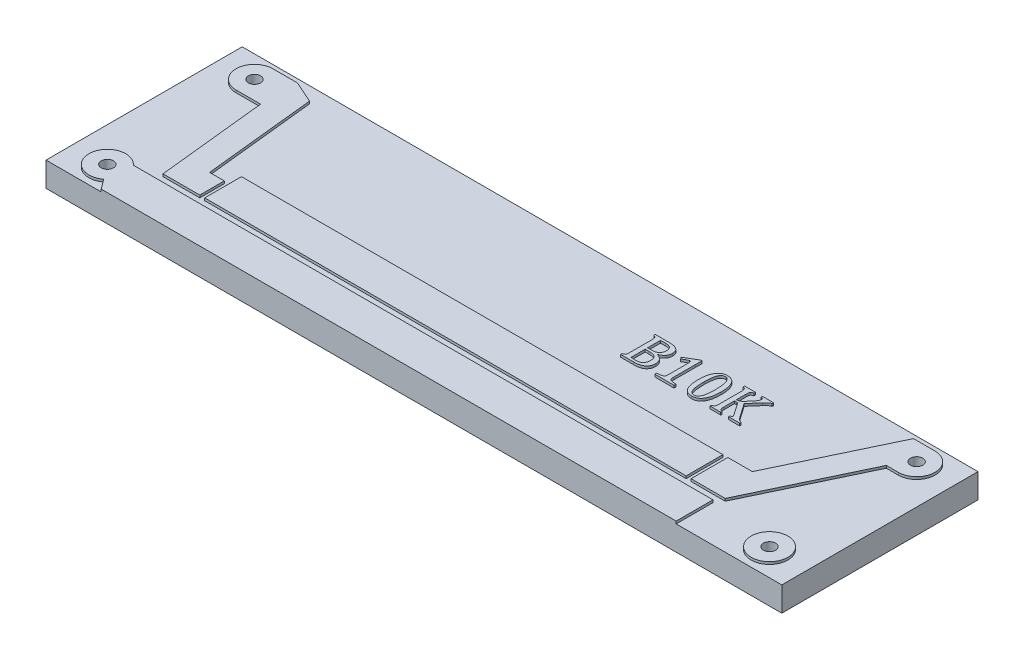
from build123d import *

# Parameters (mm, degrees)
SKETCH_1_W          = 30
SKETCH_1_H          = 8
EXTRUDE_1_DEPTH     = 1
SKETCH_2_R          = 0.25
CUT_EXTRUDE_1_DEPTH = 1.5
SKETCH_3_R          = 0.75
SKETCH_3_W          = 19.630277778
SKETCH_3_H          = 1.5
EXTRUDE_2_DEPTH     = 0.1
SKETCH_4_R          = 0.25
CUT_EXTRUDE_2_DEPTH = 10
EXTRUDE_3_DEPTH     = 0.1


with BuildPart() as part:
    # 草图1 → 凸台-拉伸1 (new body)
    with BuildSketch(Plane(origin=(0, 0, 0), x_dir=(1, 0, 0), z_dir=(0, 1, 0))):
        Rectangle(SKETCH_1_W, SKETCH_1_H)
    extrude(amount=EXTRUDE_1_DEPTH)

    # 草图2 → 切除-拉伸1 (cut, symmetric)
    with BuildSketch(Plane(origin=(0, 1, 0), x_dir=(1, 0, 0), z_dir=(0, 1, 0))):
        with Locations((-13.5, 3)):
            Circle(SKETCH_2_R)
        with Locations((13.5, 3)):
            Circle(SKETCH_2_R)
        with Locations((13.5, -3)):
            Circle(SKETCH_2_R)
        with Locations((-13.5, -3)):
            Circle(SKETCH_2_R)
    extrude(amount=CUT_EXTRUDE_1_DEPTH, both=True, mode=Mode.SUBTRACT)

    # 草图3 → 凸台-拉伸2 (add)
    with BuildSketch(Plane(origin=(0, 1, 0), x_dir=(1, 0, 0), z_dir=(0, 1, 0))):
        with Locations((13.5, -3)):
            Circle(SKETCH_3_R)
        with BuildLine():
            Line((10.693305081, -2.5), (-12.940983006, -2.5))
            ThreePointArc((-12.940983006, -2.5), (-14.246343636, -2.9260326), (-13.05, -3.6))
            Line((-13.05, -3.6), (-12.75, -4))
            Line((-12.75, -4), (10.693305081, -4))
            Line((10.693305081, -4), (10.693305081, -2.5))
        make_face()
        with BuildLine():
            Line((9.5, -0.7), (10.5, -0.7))
            Line((10.5, -0.7), (12.619047619, 3.75))
            Line((12.619047619, 3.75), (13.5, 3.75))
            ThreePointArc((13.5, 3.75), (14.25, 3), (13.5, 2.25))
            Line((13.5, 2.25), (13.0123527, 2.25))
            Line((13.0123527, 2.25), (10.893305081, -2.2))
            Line((10.893305081, -2.2), (9.5, -2.2))
            Line((9.5, -2.2), (9.5, -0.7))
        make_face()
        with BuildLine():
            Line((-13.5, 3.75), (-12.5, 3.75))
            Line((-12.5, 3.75), (-11.611050566, 3.354689573))
            Line((-11.611050566, 3.354689573), (-11.130277778, -1.2))
            Line((-11.130277778, -1.2), (-10.530277778, -1.2))
            Line((-10.530277778, -1.2), (-10.530277778, -2.2))
            Line((-10.530277778, -2.2), (-12.030277778, -2.2))
            Line((-12.030277778, -2.2), (-12.5, 2.25))
            Line((-12.5, 2.25), (-13.5, 2.25))
            ThreePointArc((-13.5, 2.25), (-14.25, 3), (-13.5, 3.75))
        make_face()
        with Locations((-0.515138889, -1.45)):
            Rectangle(SKETCH_3_W, SKETCH_3_H)
    extrude(amount=EXTRUDE_2_DEPTH)

    # 草图4 → 切除-拉伸2 (cut)
    with BuildSketch(Plane(origin=(0, 1.1, 0), x_dir=(1, 0, 0), z_dir=(0, 1, 0))):
        with Locations((13.5, 3)):
            Circle(SKETCH_4_R)
        with Locations((-13.5, 3)):
            Circle(SKETCH_4_R)
        with Locations((-13.5, -3)):
            Circle(SKETCH_4_R)
        with Locations((13.5, -3)):
            Circle(SKETCH_4_R)
    extrude(amount=-CUT_EXTRUDE_2_DEPTH, mode=Mode.SUBTRACT)

    # 草图5 → 凸台-拉伸3 (add)
    with BuildSketch(Plane(origin=(0, 1, 0), x_dir=(1, 0, 0), z_dir=(0, 1, 0))):
        with BuildLine():
            Line((3.675093502, 0.75252002), (3.675093502, 0.811316316))
            add(Edge.make_bspline(
                [(3.675093502, 0.811316316), (3.684941706, 0.81391048), (3.703100512, 0.818693782), (3.727290378, 0.827507364), (3.746416762, 0.83647328), (3.760811839, 0.846540586), (3.771095906, 0.858475927), (3.779444245, 0.87160991), (3.785625749, 0.887090397), (3.789789984, 0.905063786), (3.792793764, 0.926482094), (3.794793293, 0.952148806), (3.795989371, 0.982691887), (3.796031767, 1.004648681), (3.796054633, 1.016490892)],
                knots=[0, 0, 0, 0, 3.0539e-05, 5.6309e-05, 7.7126e-05, 9.3787e-05, 0.000108537, 0.000124086, 0.000140293, 0.000158267, 0.000179314, 0.000205127, 0.000235469, 0.000270993, 0.000270993, 0.000270993, 0.000270993], degree=3))
            Line((3.796054633, 1.016490892), (3.796054633, 1.899660259))
            add(Edge.make_bspline(
                [(3.796054633, 1.899660259), (3.79598915, 1.910582142), (3.795867337, 1.930899385), (3.795173472, 1.959002984), (3.793216667, 1.98227206), (3.790744444, 2.005850024), (3.785566123, 2.029221267), (3.775358722, 2.052060318), (3.760721587, 2.069179051), (3.74528947, 2.079976461), (3.729895844, 2.087018477), (3.714755932, 2.092828862), (3.696121377, 2.098843415), (3.682456375, 2.10273695), (3.675093502, 2.104834835)],
                knots=[0, 0, 0, 0, 3.2768e-05, 6.0956e-05, 8.4302e-05, 0.000102801, 0.000132066, 0.000155765, 0.000177056, 0.000198807, 0.000211684, 0.000227777, 0.000247436, 0.000270403, 0.000270403, 0.000270403, 0.000270403], degree=3))
            Line((3.675093502, 2.104834835), (3.675093502, 2.163631131))
            Line((3.675093502, 2.163631131), (4.238558009, 2.163631131))
            add(Edge.make_bspline(
                [(4.238558009, 2.163631131), (4.251828655, 2.16348574), (4.277766243, 2.163201571), (4.31567041, 2.161801766), (4.351594517, 2.158872546), (4.385487383, 2.155586614), (4.417251084, 2.149963574), (4.447184191, 2.144481229), (4.475113955, 2.137437524), (4.508840149, 2.126559428), (4.547123395, 2.110663419), (4.588017539, 2.087027199), (4.62237147, 2.058748963), (4.650358067, 2.025914408), (4.671642384, 1.988442146), (4.687267308, 1.946328178), (4.695884761, 1.899090215), (4.697012232, 1.866008609), (4.697597843, 1.848825961)],
                knots=[0, 0, 0, 0, 3.9815e-05, 7.7818e-05, 0.000113753, 0.000147943, 0.000179911, 0.000210481, 0.000239224, 0.000266243, 0.000316748, 0.000363281, 0.000407431, 0.000449582, 0.000491971, 0.000536057, 0.000583744, 0.000635282, 0.000635282, 0.000635282, 0.000635282], degree=3))
            add(Edge.make_bspline(
                [(4.697597843, 1.848825961), (4.697220991, 1.834404449), (4.696487344, 1.806328976), (4.689806888, 1.765791904), (4.679724156, 1.727951249), (4.664329575, 1.693532763), (4.645980007, 1.662023571), (4.624896783, 1.633223349), (4.601399105, 1.60701881), (4.574493487, 1.583853906), (4.544506862, 1.562505991), (4.51113376, 1.542081868), (4.47380282, 1.522334666), (4.447177717, 1.510484043), (4.43332074, 1.504316413)],
                knots=[0, 0, 0, 0, 4.3232e-05, 8.4163e-05, 0.000122946, 0.000160383, 0.000196886, 0.000232167, 0.000267288, 0.000302232, 0.000338436, 0.000377617, 0.000419535, 0.000465027, 0.000465027, 0.000465027, 0.000465027], degree=3))
            Line((4.43332074, 1.504316413), (4.43332074, 1.494210799))
            add(Edge.make_bspline(
                [(4.43332074, 1.494210799), (4.444707431, 1.490590303), (4.467009433, 1.48349919), (4.498810042, 1.470443937), (4.528790087, 1.456546953), (4.556274966, 1.440492785), (4.58177166, 1.423344192), (4.605355114, 1.404969329), (4.626367503, 1.384668022), (4.64548611, 1.363215701), (4.662269944, 1.340493009), (4.677192258, 1.316879282), (4.689425315, 1.291869057), (4.699491525, 1.265827495), (4.707577206, 1.238826744), (4.712988853, 1.210711141), (4.716451295, 1.181635475), (4.716946087, 1.161858339), (4.717196608, 1.151844866)],
                knots=[0, 0, 0, 0, 3.583e-05, 7.0177e-05, 0.000103053, 0.000134883, 0.000165544, 0.000195196, 0.000224436, 0.000253072, 0.000281306, 0.000309093, 0.000336757, 0.000364679, 0.000392779, 0.000421186, 0.000450473, 0.000480508, 0.000480508, 0.000480508, 0.000480508], degree=3))
            add(Edge.make_bspline(
                [(4.717196608, 1.151844866), (4.717059852, 1.140302097), (4.716793084, 1.117785687), (4.713560879, 1.084861856), (4.708763744, 1.053650799), (4.702026758, 1.023934921), (4.693198611, 0.995876534), (4.682386397, 0.969383584), (4.669963215, 0.944422749), (4.650218555, 0.913944758), (4.621397241, 0.879126927), (4.580300922, 0.843245694), (4.532574638, 0.813933621), (4.478886881, 0.790756064), (4.419160036, 0.773429599), (4.353667678, 0.761612432), (4.282338712, 0.753660428), (4.232763129, 0.752909836), (4.207016245, 0.75252002)],
                knots=[0, 0, 0, 0, 3.4616e-05, 6.7526e-05, 9.9143e-05, 0.000129303, 0.000158843, 0.000187277, 0.000215078, 0.000242346, 0.000296062, 0.000350106, 0.000405256, 0.000463401, 0.000525028, 0.000591395, 0.000662852, 0.000740061, 0.000740061, 0.000740061, 0.000740061], degree=3))
            Line((4.207016245, 0.75252002), (3.675093502, 0.75252002))
        make_face()
        with BuildLine():
            add(Edge.make_bspline(
                [(4.167818715, 1.536470637), (4.180177863, 1.536715916), (4.204127252, 1.537191214), (4.239041435, 1.540573947), (4.271748264, 1.546251306), (4.302170928, 1.554540814), (4.330257531, 1.564996441), (4.356220727, 1.577525232), (4.379963181, 1.592626216), (4.401447839, 1.610096688), (4.420558405, 1.629837428), (4.437249794, 1.651651952), (4.451054034, 1.675821025), (4.462358439, 1.701933032), (4.471269725, 1.730044898), (4.47771589, 1.760177922), (4.481339212, 1.792492178), (4.481783013, 1.814723266), (4.482011423, 1.826164889)],
                knots=[0, 0, 0, 0, 3.7074e-05, 7.1842e-05, 0.000105121, 0.000136545, 0.000166294, 0.000194918, 0.000222867, 0.000250511, 0.000277798, 0.000305115, 0.000332691, 0.000361079, 0.000390327, 0.000421019, 0.000453383, 0.000487702, 0.000487702, 0.000487702, 0.000487702], degree=3))
            add(Edge.make_bspline(
                [(4.482011423, 1.826164889), (4.481665151, 1.837297328), (4.480998862, 1.858718136), (4.477416871, 1.88944673), (4.469788603, 1.91698984), (4.460101412, 1.941741826), (4.447641594, 1.963842444), (4.432894738, 1.983374178), (4.416260138, 2.000948198), (4.397074865, 2.015431364), (4.376295078, 2.028254028), (4.35360842, 2.038768161), (4.329212747, 2.047911811), (4.293538368, 2.056568687), (4.245621086, 2.06438517), (4.206238324, 2.065210694), (4.185886326, 2.065637304)],
                knots=[0, 0, 0, 0, 3.3414e-05, 6.4295e-05, 9.2523e-05, 0.000118909, 0.000143864, 0.000168363, 0.000192186, 0.000216197, 0.000240251, 0.000265319, 0.00029109, 0.000318274, 0.000375316, 0.000436318, 0.000436318, 0.000436318, 0.000436318], degree=3))
            add(Edge.make_bspline(
                [(4.185886326, 2.065637304), (4.179046546, 2.065683703), (4.164343471, 2.065783444), (4.140770508, 2.064911579), (4.114122234, 2.064471681), (4.085646689, 2.063484546), (4.057575509, 2.062602433), (4.032246112, 2.061860558), (4.010828356, 2.060459167), (3.997861338, 2.059805864), (3.992042287, 2.05951269)],
                knots=[0, 0, 0, 0, 2.0517e-05, 4.4105e-05, 7.0754e-05, 0.000100473, 0.000129579, 0.000155013, 0.000176484, 0.000193963, 0.000193963, 0.000193963, 0.000193963], degree=3))
            Line((3.992042287, 2.05951269), (3.992042287, 1.536470637))
            Line((3.992042287, 1.536470637), (4.167818715, 1.536470637))
        make_face(mode=Mode.SUBTRACT)
        with BuildLine():
            add(Edge.make_bspline(
                [(3.992042287, 0.857557153), (4.004694354, 0.856455504), (4.030688471, 0.854192127), (4.070833433, 0.852283466), (4.113090006, 0.850497226), (4.141991029, 0.850508217), (4.156794409, 0.850513847)],
                knots=[0, 0, 0, 0, 3.8096e-05, 7.8269e-05, 0.000120557, 0.000164961, 0.000164961, 0.000164961, 0.000164961], degree=3))
            add(Edge.make_bspline(
                [(4.156794409, 0.850513847), (4.177636871, 0.850872698), (4.217085008, 0.85155189), (4.272451687, 0.857902591), (4.320616172, 0.868016616), (4.361846295, 0.882546623), (4.396466687, 0.902081717), (4.426288137, 0.924746049), (4.450349245, 0.952222219), (4.469764223, 0.983447035), (4.483996158, 1.018972633), (4.494362581, 1.058354948), (4.500430655, 1.101947249), (4.50120594, 1.132328677), (4.501610188, 1.148170097)],
                knots=[0, 0, 0, 0, 6.2508e-05, 0.000118307, 0.000166902, 0.000209914, 0.000248848, 0.000285725, 0.000321735, 0.000357766, 0.000395527, 0.000436084, 0.000479695, 0.000527209, 0.000527209, 0.000527209, 0.000527209], degree=3))
            add(Edge.make_bspline(
                [(4.501610188, 1.148170097), (4.501257896, 1.163915423), (4.500581741, 1.194135392), (4.493825507, 1.237361398), (4.4825446, 1.276301829), (4.466931097, 1.311131902), (4.446429178, 1.34188808), (4.420555817, 1.36803342), (4.390107644, 1.390528101), (4.354094214, 1.40831891), (4.312363363, 1.422129346), (4.264015286, 1.431546198), (4.208811031, 1.43776414), (4.169573579, 1.438230362), (4.148832411, 1.43847681)],
                knots=[0, 0, 0, 0, 4.7208e-05, 9.0607e-05, 0.000130821, 0.000168507, 0.000204689, 0.00024107, 0.00027831, 0.000317752, 0.000361038, 0.000409805, 0.000465266, 0.000527458, 0.000527458, 0.000527458, 0.000527458], degree=3))
            Line((4.148832411, 1.43847681), (3.992042287, 1.43847681))
            Line((3.992042287, 1.43847681), (3.992042287, 0.857557153))
        make_face(mode=Mode.SUBTRACT)
        with BuildLine():
            add(Edge.make_bspline(
                [(5.559943522, 1.025371582), (5.5599119, 1.01597523), (5.559852731, 0.998392676), (5.561731365, 0.973915842), (5.563129847, 0.952989397), (5.567062448, 0.930806326), (5.57470515, 0.907509455), (5.58984609, 0.883801888), (5.613068919, 0.866558745), (5.642833415, 0.853333749), (5.680474364, 0.844672753), (5.716886032, 0.838867766), (5.751214813, 0.835928791), (5.781944535, 0.833832197), (5.816649346, 0.831911116), (5.841060844, 0.831258822), (5.853925003, 0.830915082)],
                knots=[0, 0, 0, 0, 2.8175e-05, 5.2721e-05, 7.3626e-05, 9.1046e-05, 0.000120196, 0.000146695, 0.000173956, 0.000205611, 0.000243862, 0.000289425, 0.00031618, 0.000347183, 0.000381836, 0.00042044, 0.00042044, 0.00042044, 0.00042044], degree=3))
            Line((5.853925003, 0.830915082), (5.853925003, 0.75252002))
            Line((5.853925003, 0.75252002), (5.069974386, 0.75252002))
            Line((5.069974386, 0.75252002), (5.069974386, 0.830915082))
            add(Edge.make_bspline(
                [(5.069974386, 0.830915082), (5.088047143, 0.831742573), (5.12145711, 0.833272303), (5.167396807, 0.836666779), (5.20498529, 0.840216093), (5.235187181, 0.844073118), (5.259752912, 0.849108382), (5.280463772, 0.855107735), (5.298296237, 0.862136839), (5.313348966, 0.870428759), (5.32599325, 0.880476098), (5.336368424, 0.892356785), (5.345544535, 0.905532607), (5.352322081, 0.921393671), (5.35814645, 0.940409393), (5.361225887, 0.964153953), (5.363902447, 0.99274733), (5.363937113, 1.013520749), (5.363955867, 1.024759121)],
                knots=[0, 0, 0, 0, 5.4273e-05, 0.000100331, 0.000138176, 0.000167539, 0.000191623, 0.000213328, 0.000232151, 0.000249016, 0.000264702, 0.000280317, 0.0002962, 0.000312648, 0.000331831, 0.000355695, 0.00038428, 0.000417971, 0.000417971, 0.000417971, 0.000417971], degree=3))
            Line((5.363955867, 1.024759121), (5.363955867, 1.86138142))
            add(Edge.make_bspline(
                [(5.363955867, 1.86138142), (5.363817989, 1.867826737), (5.36356259, 1.879765702), (5.360766959, 1.896342551), (5.356469396, 1.910292584), (5.349721611, 1.921495686), (5.341485461, 1.930331678), (5.331109735, 1.936284785), (5.319207126, 1.940120389), (5.310602406, 1.940497106), (5.306078263, 1.940695174)],
                knots=[0, 0, 0, 0, 1.9314e-05, 3.5777e-05, 5.0303e-05, 6.2802e-05, 7.4714e-05, 8.611e-05, 9.8313e-05, 0.000111843, 0.000111843, 0.000111843, 0.000111843], degree=3))
            add(Edge.make_bspline(
                [(5.306078263, 1.940695174), (5.299917194, 1.94018634), (5.28610667, 1.939045749), (5.263895522, 1.931941754), (5.238303504, 1.920641762), (5.208929288, 1.905634717), (5.176395343, 1.886329293), (5.139839139, 1.864358701), (5.099750523, 1.838876801), (5.071984774, 1.820495921), (5.057418927, 1.810853353)],
                knots=[0, 0, 0, 0, 1.8498e-05, 4.1466e-05, 6.9452e-05, 0.000102458, 0.000140328, 0.000182921, 0.000230411, 0.000282816, 0.000282816, 0.000282816, 0.000282816], degree=3))
            Line((5.057418927, 1.810853353), (5.01117809, 1.890473338))
            Line((5.01117809, 1.890473338), (5.506965609, 2.183229896))
            Line((5.506965609, 2.183229896), (5.566068136, 2.183229896))
            add(Edge.make_bspline(
                [(5.566068136, 2.183229896), (5.565530236, 2.174554873), (5.564404284, 2.156395971), (5.563211018, 2.128013133), (5.562397529, 2.097281166), (5.56134528, 2.064111333), (5.56089079, 2.028480685), (5.560159586, 1.990511236), (5.55988384, 1.950188686), (5.559923192, 1.922525475), (5.559943522, 1.908234719)],
                knots=[0, 0, 0, 0, 2.6075e-05, 5.458e-05, 8.5217e-05, 0.000118303, 0.000154137, 0.000192115, 0.000232232, 0.000275104, 0.000275104, 0.000275104, 0.000275104], degree=3))
            Line((5.559943522, 1.908234719), (5.559943522, 1.025371582))
        make_face()
        with BuildLine():
            add(Edge.make_bspline(
                [(6.587347553, 0.732921255), (6.569348192, 0.73341637), (6.534373099, 0.734378443), (6.483767868, 0.742804919), (6.436703198, 0.756561226), (6.393126627, 0.776023428), (6.352984456, 0.80086689), (6.316792662, 0.831726227), (6.284166328, 0.867920428), (6.25485781, 0.909605479), (6.229605033, 0.957170501), (6.207546287, 1.010191399), (6.188942454, 1.068802011), (6.174198842, 1.13317812), (6.162274884, 1.203100921), (6.153801596, 1.278754296), (6.149043411, 1.360122292), (6.148293907, 1.416217803), (6.147906485, 1.445213886)],
                knots=[0, 0, 0, 0, 5.3967e-05, 0.000104865, 0.000153409, 0.000200702, 0.000247607, 0.000294541, 0.000342888, 0.000393439, 0.000447012, 0.000504112, 0.000565513, 0.000631251, 0.000702085, 0.000778209, 0.000859508, 0.000946497, 0.000946497, 0.000946497, 0.000946497], degree=3))
            add(Edge.make_bspline(
                [(6.147906485, 1.445213886), (6.148318058, 1.475949365), (6.149113362, 1.535341082), (6.155176201, 1.621130599), (6.165398033, 1.700531838), (6.180112838, 1.773549857), (6.198312808, 1.840417681), (6.220090271, 1.901156064), (6.245011636, 1.955945977), (6.273661492, 2.004603042), (6.305083686, 2.04769551), (6.340305809, 2.084171686), (6.377921471, 2.115517537), (6.418989256, 2.140196509), (6.462322454, 2.159793417), (6.507943394, 2.172983395), (6.555265701, 2.181755428), (6.587511415, 2.182733358), (6.603884012, 2.183229896)],
                knots=[0, 0, 0, 0, 9.22e-05, 0.000178163, 0.000257854, 0.000332204, 0.000401445, 0.000465571, 0.000525586, 0.00058173, 0.000634709, 0.000685174, 0.00073348, 0.000781168, 0.000828461, 0.000875743, 0.00092332, 0.000972395, 0.000972395, 0.000972395, 0.000972395], degree=3))
            add(Edge.make_bspline(
                [(6.603884012, 2.183229896), (6.622086588, 2.182734625), (6.657465738, 2.181771998), (6.708782493, 2.173326356), (6.756479272, 2.159551065), (6.800888938, 2.140617538), (6.841192266, 2.115436423), (6.878213486, 2.08519948), (6.910918836, 2.04885553), (6.94061458, 2.007576616), (6.966212202, 1.960395164), (6.989024087, 1.908041617), (7.007271366, 1.849696417), (7.023115361, 1.78615063), (7.034579726, 1.716785206), (7.043701026, 1.64202433), (7.048273462, 1.56153618), (7.049048785, 1.506056145), (7.049449694, 1.47736811)],
                knots=[0, 0, 0, 0, 5.4579e-05, 0.000106081, 0.000155507, 0.000203236, 0.000250402, 0.00029761, 0.000346163, 0.000396642, 0.000449824, 0.000506882, 0.0005677, 0.000632985, 0.000703216, 0.000778462, 0.000858844, 0.000944915, 0.000944915, 0.000944915, 0.000944915], degree=3))
            add(Edge.make_bspline(
                [(7.049449694, 1.47736811), (7.049123671, 1.447654279), (7.04849231, 1.390111861), (7.042882728, 1.306512335), (7.033930096, 1.22848312), (7.021092439, 1.155966577), (7.004883185, 1.088999156), (6.98413472, 1.027779513), (6.960551511, 0.971821996), (6.932963687, 0.921544052), (6.90163795, 0.87714407), (6.866870178, 0.838484004), (6.828745989, 0.805733376), (6.787001064, 0.778957418), (6.741884297, 0.758099124), (6.693257052, 0.743325679), (6.641345094, 0.734728749), (6.605651729, 0.733533962), (6.587347553, 0.732921255)],
                knots=[0, 0, 0, 0, 8.9132e-05, 0.000172609, 0.000251236, 0.000324642, 0.000393418, 0.000457719, 0.000518356, 0.000575375, 0.000629414, 0.000681016, 0.000730972, 0.000779731, 0.00082933, 0.000879605, 0.000931761, 0.000986662, 0.000986662, 0.000986662, 0.000986662], degree=3))
        make_face()
        with BuildLine():
            add(Edge.make_bspline(
                [(6.343894139, 1.476449418), (6.344026113, 1.448782984), (6.344281384, 1.395269153), (6.347481819, 1.317870296), (6.352136359, 1.24615026), (6.359177648, 1.180266974), (6.367987528, 1.120079378), (6.37847205, 1.065522019), (6.391231131, 1.016567678), (6.406201401, 0.973264905), (6.422934497, 0.935027677), (6.442226778, 0.90218563), (6.463438769, 0.874027297), (6.487127459, 0.851064841), (6.51326202, 0.833263221), (6.541550245, 0.820590051), (6.57200428, 0.812553113), (6.593115434, 0.811734091), (6.603884012, 0.811316316)],
                knots=[0, 0, 0, 0, 8.2994e-05, 0.00016053, 0.000232356, 0.000298571, 0.000359246, 0.000414799, 0.000465159, 0.000510871, 0.000552131, 0.000590156, 0.000624884, 0.000657588, 0.000688675, 0.000719239, 0.000750211, 0.000782458, 0.000782458, 0.000782458, 0.000782458], degree=3))
            add(Edge.make_bspline(
                [(6.603884012, 0.811316316), (6.614133178, 0.811792169), (6.634269175, 0.812727052), (6.663301499, 0.819936119), (6.690427928, 0.831821517), (6.715144043, 0.848839714), (6.737915045, 0.870473074), (6.758382852, 0.896756273), (6.776838071, 0.927729826), (6.792913971, 0.96358341), (6.807256193, 1.004259891), (6.819791593, 1.049992652), (6.829878694, 1.10101559), (6.838846616, 1.156961209), (6.845511379, 1.218182744), (6.849771786, 1.284499463), (6.85310783, 1.356067587), (6.853341111, 1.405501543), (6.85346204, 1.431127273)],
                knots=[0, 0, 0, 0, 3.0721e-05, 6.0356e-05, 8.9148e-05, 0.00011913, 0.000149891, 0.000183035, 0.000218747, 0.000257802, 0.00030071, 0.000348035, 0.000399924, 0.000456664, 0.000517975, 0.000584586, 0.000656003, 0.000732872, 0.000732872, 0.000732872, 0.000732872], degree=3))
            add(Edge.make_bspline(
                [(6.85346204, 1.431127273), (6.85329367, 1.450828477), (6.852964752, 1.489315605), (6.851882984, 1.54567815), (6.849514409, 1.599191628), (6.845645989, 1.649701633), (6.841614652, 1.697326867), (6.836002705, 1.742036401), (6.82966399, 1.783920402), (6.822360567, 1.822953989), (6.813961803, 1.859157107), (6.805327629, 1.892869072), (6.795312431, 1.9238273), (6.785339295, 1.952411903), (6.773319715, 1.97778973), (6.761667423, 2.000971478), (6.748694379, 2.021350391), (6.73078131, 2.044425036), (6.706569057, 2.068656381), (6.673392904, 2.089754453), (6.636963912, 2.102715326), (6.611541405, 2.10412272), (6.59867809, 2.104834835)],
                knots=[0, 0, 0, 0, 5.9106e-05, 0.000115465, 0.000169112, 0.000219773, 0.000267432, 0.000312481, 0.000354924, 0.000394504, 0.000431573, 0.000466409, 0.000498854, 0.000529177, 0.000557131, 0.000583018, 0.000606975, 0.000629455, 0.000670599, 0.000709001, 0.000746576, 0.000785061, 0.000785061, 0.000785061, 0.000785061], degree=3))
            add(Edge.make_bspline(
                [(6.59867809, 2.104834835), (6.587096918, 2.104310187), (6.564563613, 2.103289389), (6.532203114, 2.095207154), (6.502765136, 2.081491568), (6.47651718, 2.062085629), (6.453017745, 2.037751465), (6.432212464, 2.008651999), (6.413842315, 1.974844544), (6.397674557, 1.936475612), (6.384124668, 1.893449279), (6.372501635, 1.846085294), (6.363139912, 1.794324633), (6.355938686, 1.738296746), (6.350572255, 1.678220452), (6.346524568, 1.614301775), (6.344564748, 1.546588358), (6.344121549, 1.50023424), (6.343894139, 1.476449418)],
                knots=[0, 0, 0, 0, 3.4714e-05, 6.7542e-05, 9.9325e-05, 0.000131543, 0.000164893, 0.000200421, 0.000238523, 0.000280101, 0.000325133, 0.000373707, 0.000426324, 0.000482844, 0.000543117, 0.000607243, 0.000674954, 0.000746312, 0.000746312, 0.000746312, 0.000746312], degree=3))
        make_face(mode=Mode.SUBTRACT)
        with BuildLine():
            Line((7.636493965, 1.516871872), (7.667423267, 1.516871872))
            add(Edge.make_bspline(
                [(7.667423267, 1.516871872), (7.680034274, 1.51741676), (7.704395506, 1.518469343), (7.734151205, 1.526466273), (7.756690794, 1.536804496), (7.774587457, 1.54731244), (7.793026217, 1.561015977), (7.809460878, 1.574018994), (7.823162985, 1.58692826), (7.835636949, 1.598020678), (7.848608857, 1.611906878), (7.863704237, 1.626833647), (7.879523638, 1.644279513), (7.897136479, 1.663131138), (7.915579548, 1.684272447), (7.928428723, 1.698879871), (7.935068907, 1.706428681)],
                knots=[0, 0, 0, 0, 3.7791e-05, 7.3002e-05, 9.1503e-05, 0.000112091, 0.000135124, 0.000160376, 0.000174899, 0.000191585, 0.000210425, 0.000231863, 0.000255265, 0.000281056, 0.000309259, 0.000339421, 0.000339421, 0.000339421, 0.000339421], degree=3))
            add(Edge.make_bspline(
                [(7.935068907, 1.706428681), (7.943061952, 1.715486638), (7.958432185, 1.732904646), (7.980061158, 1.758406384), (8.000065327, 1.781696739), (8.018155633, 1.803031733), (8.033999955, 1.822597727), (8.047896503, 1.840146744), (8.059775096, 1.85571415), (8.06706112, 1.865459425), (8.070422881, 1.86995588)],
                knots=[0, 0, 0, 0, 3.624e-05, 6.9688e-05, 0.000100313, 0.000128347, 0.0001536, 0.000175839, 0.0001955, 0.000212343, 0.000212343, 0.000212343, 0.000212343], degree=3))
            add(Edge.make_bspline(
                [(8.070422881, 1.86995588), (8.077453236, 1.879591973), (8.090659234, 1.897692657), (8.107974626, 1.924166738), (8.121797775, 1.948144897), (8.128342779, 1.964001601), (8.131362792, 1.971318245)],
                knots=[0, 0, 0, 0, 3.5777e-05, 6.7204e-05, 9.4895e-05, 0.00011862, 0.00011862, 0.00011862, 0.00011862], degree=3))
            add(Edge.make_bspline(
                [(8.131362792, 1.971318245), (8.135061944, 1.980486881), (8.142130773, 1.998007529), (8.143341232, 2.016846745), (8.143918252, 2.025827312)],
                knots=[0, 0, 0, 0, 2.944e-05, 5.6257e-05, 5.6257e-05, 5.6257e-05, 5.6257e-05], degree=3))
            add(Edge.make_bspline(
                [(8.143918252, 2.025827312), (8.143629255, 2.031974397), (8.143086404, 2.043521081), (8.138952732, 2.059717365), (8.131073652, 2.073006677), (8.120108019, 2.083326752), (8.107067143, 2.091605363), (8.091754363, 2.09806713), (8.074210445, 2.10261693), (8.06167016, 2.104073185), (8.055111346, 2.104834835)],
                knots=[0, 0, 0, 0, 1.8438e-05, 3.4633e-05, 4.9601e-05, 6.411e-05, 7.9401e-05, 9.5726e-05, 0.000113775, 0.000133567, 0.000133567, 0.000133567, 0.000133567], degree=3))
            Line((8.055111346, 2.104834835), (8.055111346, 2.163631131))
            Line((8.055111346, 2.163631131), (8.50557672, 2.163631131))
            Line((8.50557672, 2.163631131), (8.50557672, 2.104834835))
            add(Edge.make_bspline(
                [(8.50557672, 2.104834835), (8.494546771, 2.102100714), (8.47200781, 2.096513721), (8.439343692, 2.081563865), (8.40650531, 2.061379309), (8.378646688, 2.039719958), (8.354516926, 2.016736349), (8.331600911, 1.993994661), (8.305338912, 1.96513831), (8.286404516, 1.944074361), (8.276209918, 1.932733176)],
                knots=[0, 0, 0, 0, 3.403e-05, 6.9538e-05, 0.000107195, 0.000149523, 0.00017509, 0.000207137, 0.00024636, 0.000292111, 0.000292111, 0.000292111, 0.000292111], degree=3))
            Line((8.276209918, 1.932733176), (7.928944293, 1.534327022))
            Line((7.928944293, 1.534327022), (8.304995605, 0.995360973))
            add(Edge.make_bspline(
                [(8.304995605, 0.995360973), (8.314398201, 0.98212538), (8.331771316, 0.957670059), (8.357017642, 0.924889207), (8.378355521, 0.898259485), (8.40256984, 0.873262225), (8.430111623, 0.850287798), (8.462946255, 0.83034176), (8.496250617, 0.817606024), (8.518964131, 0.81342032), (8.530381407, 0.811316316)],
                knots=[0, 0, 0, 0, 4.8699e-05, 8.9981e-05, 0.000124133, 0.000150987, 0.000194274, 0.000231352, 0.00026576, 0.000300537, 0.000300537, 0.000300537, 0.000300537], degree=3))
            Line((8.530381407, 0.811316316), (8.530381407, 0.75252002))
            Line((8.530381407, 0.75252002), (8.074710111, 0.75252002))
            Line((8.074710111, 0.75252002), (8.074710111, 0.811316316))
            add(Edge.make_bspline(
                [(8.074710111, 0.811316316), (8.080645984, 0.811698538), (8.091762012, 0.812414319), (8.106981139, 0.815282236), (8.11977807, 0.818487613), (8.13009215, 0.822693713), (8.138245915, 0.82808399), (8.144260292, 0.834732988), (8.147430551, 0.843026264), (8.147940073, 0.848754799), (8.148205482, 0.85173877)],
                knots=[0, 0, 0, 0, 1.7827e-05, 3.3385e-05, 4.6384e-05, 5.7362e-05, 6.662e-05, 7.5522e-05, 8.3767e-05, 9.2732e-05, 9.2732e-05, 9.2732e-05, 9.2732e-05], degree=3))
            add(Edge.make_bspline(
                [(8.148205482, 0.85173877), (8.147467711, 0.858542549), (8.145810213, 0.873828118), (8.135648573, 0.898238539), (8.120150505, 0.927271131), (8.106290217, 0.947425315), (8.098596107, 0.958613288)],
                knots=[0, 0, 0, 0, 2.0442e-05, 4.5925e-05, 7.853e-05, 0.000119214, 0.000119214, 0.000119214, 0.000119214], degree=3))
            Line((8.098596107, 0.958613288), (7.857592538, 1.311084835))
            add(Edge.make_bspline(
                [(7.857592538, 1.311084835), (7.851155319, 1.32084936), (7.839367546, 1.338730064), (7.821972881, 1.362200976), (7.808113286, 1.381047136), (7.793449098, 1.398654548), (7.776409783, 1.415290224), (7.757214803, 1.426833756), (7.740467788, 1.433120604), (7.726063469, 1.436420127), (7.709726117, 1.438150059), (7.69825448, 1.438364274), (7.692227955, 1.43847681)],
                knots=[0, 0, 0, 0, 3.5078e-05, 6.4234e-05, 8.763e-05, 0.000105235, 0.000132966, 0.000158647, 0.000171729, 0.000186511, 0.000202845, 0.000220923, 0.000220923, 0.000220923, 0.000220923], degree=3))
            Line((7.692227955, 1.43847681), (7.637412657, 1.43847681))
            Line((7.637412657, 1.43847681), (7.637412657, 1.014653508))
            add(Edge.make_bspline(
                [(7.637412657, 1.014653508), (7.637446033, 1.004137983), (7.637507938, 0.984633526), (7.638577975, 0.957586522), (7.639487583, 0.934981819), (7.642154664, 0.911940652), (7.647352598, 0.88903517), (7.656140076, 0.865851078), (7.670946599, 0.848162407), (7.686795168, 0.836683083), (7.702815859, 0.828697446), (7.71858344, 0.823214009), (7.737285019, 0.816905451), (7.750997694, 0.813271195), (7.758373788, 0.811316316)],
                knots=[0, 0, 0, 0, 3.1543e-05, 5.8507e-05, 8.1201e-05, 9.9396e-05, 0.000127995, 0.000151599, 0.00017293, 0.000196143, 0.000209838, 0.000226504, 0.000246163, 0.000269046, 0.000269046, 0.000269046, 0.000269046], degree=3))
            Line((7.758373788, 0.811316316), (7.758373788, 0.75252002))
            Line((7.758373788, 0.75252002), (7.320463873, 0.75252002))
            Line((7.320463873, 0.75252002), (7.320463873, 0.811316316))
            add(Edge.make_bspline(
                [(7.320463873, 0.811316316), (7.330312076, 0.81391048), (7.348470883, 0.818693782), (7.372660749, 0.827507364), (7.391787132, 0.83647328), (7.40618221, 0.846540586), (7.416466276, 0.858475927), (7.424814616, 0.87160991), (7.43099612, 0.887090397), (7.435160354, 0.905063786), (7.438164134, 0.926482094), (7.440163664, 0.952148806), (7.441359741, 0.982691887), (7.441402137, 1.004648681), (7.441425003, 1.016490892)],
                knots=[0, 0, 0, 0, 3.0539e-05, 5.6309e-05, 7.7126e-05, 9.3787e-05, 0.000108537, 0.000124086, 0.000140293, 0.000158267, 0.000179314, 0.000205127, 0.000235469, 0.000270993, 0.000270993, 0.000270993, 0.000270993], degree=3))
            Line((7.441425003, 1.016490892), (7.441425003, 1.899660259))
            add(Edge.make_bspline(
                [(7.441425003, 1.899660259), (7.44135952, 1.910582142), (7.441237707, 1.930899385), (7.440543842, 1.959002984), (7.438587037, 1.98227206), (7.436114814, 2.005850024), (7.430936494, 2.029221267), (7.420729092, 2.052060318), (7.406091957, 2.069179051), (7.390659841, 2.079976461), (7.375266214, 2.087018477), (7.360126303, 2.092828862), (7.341491747, 2.098843415), (7.327826745, 2.10273695), (7.320463873, 2.104834835)],
                knots=[0, 0, 0, 0, 3.2768e-05, 6.0956e-05, 8.4302e-05, 0.000102801, 0.000132066, 0.000155765, 0.000177056, 0.000198807, 0.000211684, 0.000227777, 0.000247436, 0.000270403, 0.000270403, 0.000270403, 0.000270403], degree=3))
            Line((7.320463873, 2.104834835), (7.320463873, 2.163631131))
            Line((7.320463873, 2.163631131), (7.758373788, 2.163631131))
            Line((7.758373788, 2.163631131), (7.758373788, 2.104834835))
            add(Edge.make_bspline(
                [(7.758373788, 2.104834835), (7.75132033, 2.102932795), (7.738281685, 2.099416785), (7.720208871, 2.093968039), (7.705327789, 2.088310528), (7.689971282, 2.080736484), (7.674583707, 2.069827328), (7.66214572, 2.056460551), (7.654659873, 2.043570565), (7.65015432, 2.031643447), (7.646339323, 2.017675045), (7.642760289, 2.001254382), (7.640493937, 1.98146741), (7.638713152, 1.957463149), (7.637467483, 1.928764403), (7.637431806, 1.908031944), (7.637412657, 1.896904183)],
                knots=[0, 0, 0, 0, 2.1916e-05, 4.0513e-05, 5.6607e-05, 6.9618e-05, 9.1796e-05, 0.000112828, 0.000123805, 0.000136316, 0.000150954, 0.00016723, 0.000186678, 0.000210634, 0.000239446, 0.000272827, 0.000272827, 0.000272827, 0.000272827], degree=3))
            Line((7.637412657, 1.896904183), (7.636493965, 1.516871872))
        make_face()
    extrude(amount=EXTRUDE_3_DEPTH)


solid = part.part
